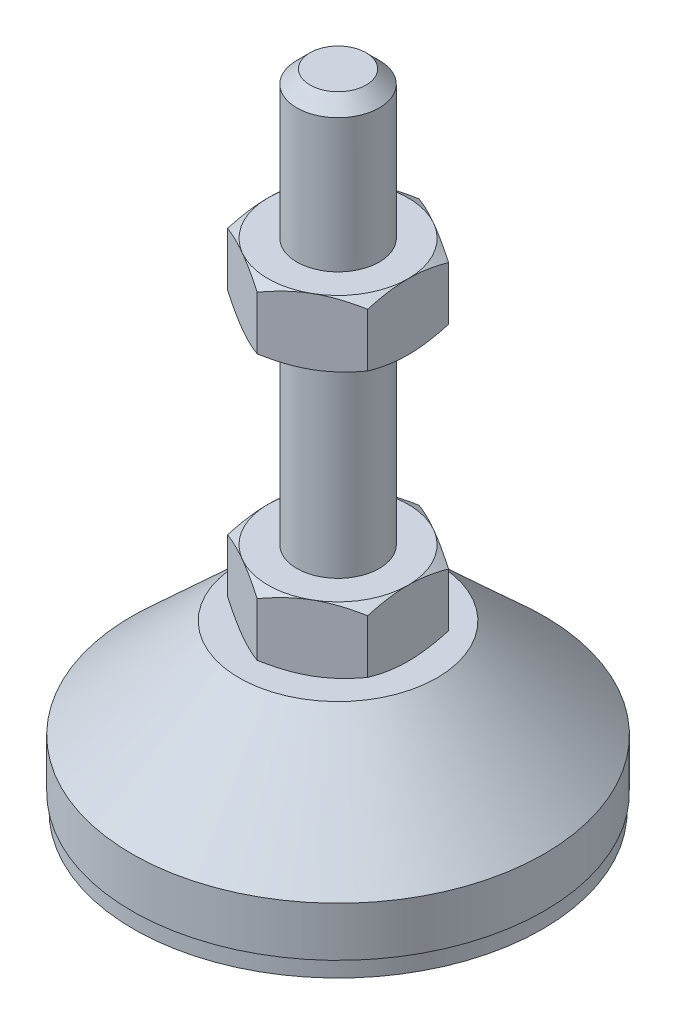
from build123d import *

# Parameters (mm, degrees)
EXTRUDE_1_DEPTH = 8
EXTRUDE_2_DEPTH = 8


with BuildPart() as part:
    # Эскиз1 → Повернуть1 (revolve)
    with BuildSketch(Plane.XY, mode=Mode.PRIVATE) as revolve_1_sk:
        Polygon((0, 0), (-24.8, 0), (-24.8, 2), (-25, 2), (-25, 8), (-12, 20), (-5, 20), (-5, 28), (-5, 76.4), (-3.4, 78), (0, 78), align=None)
    revolve(revolve_1_sk.sketch.rotate(Axis((0, 0, 0), (0, 1, 0)), 180), axis=Axis((0, 0, 0), (0, 1, 0)))  # turned: the seam where the file's is

    # Эскиз2 → Бобышка-Вытянуть1 (add)
    with BuildSketch(Plane(origin=(0, 20, 0), x_dir=(1, 0, 0), z_dir=(0, 1, 0))):
        Polygon((0, 9.814954576), (-8.5, 4.907477288), (-8.5, -4.907477288), (0, -9.814954576), (8.5, -4.907477288), (8.5, 4.907477288), align=None)
    extrude(amount=EXTRUDE_1_DEPTH)

    # Эскиз3 → Бобышка-Вытянуть2 (add)
    with BuildSketch(Plane(origin=(0, 52.2, 0), x_dir=(1, 0, 0), z_dir=(0, 1, 0))):
        Polygon((8.5, 4.907477288), (0, 9.814954576), (-8.5, 4.907477288), (-8.5, -4.907477288), (0, -9.814954576), (8.5, -4.907477288), align=None)
    extrude(amount=EXTRUDE_2_DEPTH)

    # Эскиз4 → Вырез-Повернуть2 (revolve, cut)
    with BuildSketch(Plane.XY, mode=Mode.PRIVATE) as cut_revolve_2_sk:
        Polygon((-15.42820323, 60.2), (-8.5, 60.2), (-15.42820323, 56.2), align=None)
        Polygon((-15.42820323, 52.2), (-15.42820323, 56.2), (-8.5, 52.2), align=None)
        Polygon((-15.42820323, 28), (-15.42820323, 24), (-8.5, 28), align=None)
        Polygon((-15.42820323, 24), (-15.42820323, 20), (-8.5, 20), align=None)
    revolve(cut_revolve_2_sk.sketch.rotate(Axis((0, 78, 0), (0, 1, 0)), 180), axis=Axis((0, 78, 0), (0, 1, 0)), mode=Mode.SUBTRACT)  # turned: the seam where the file's is


solid = part.part
